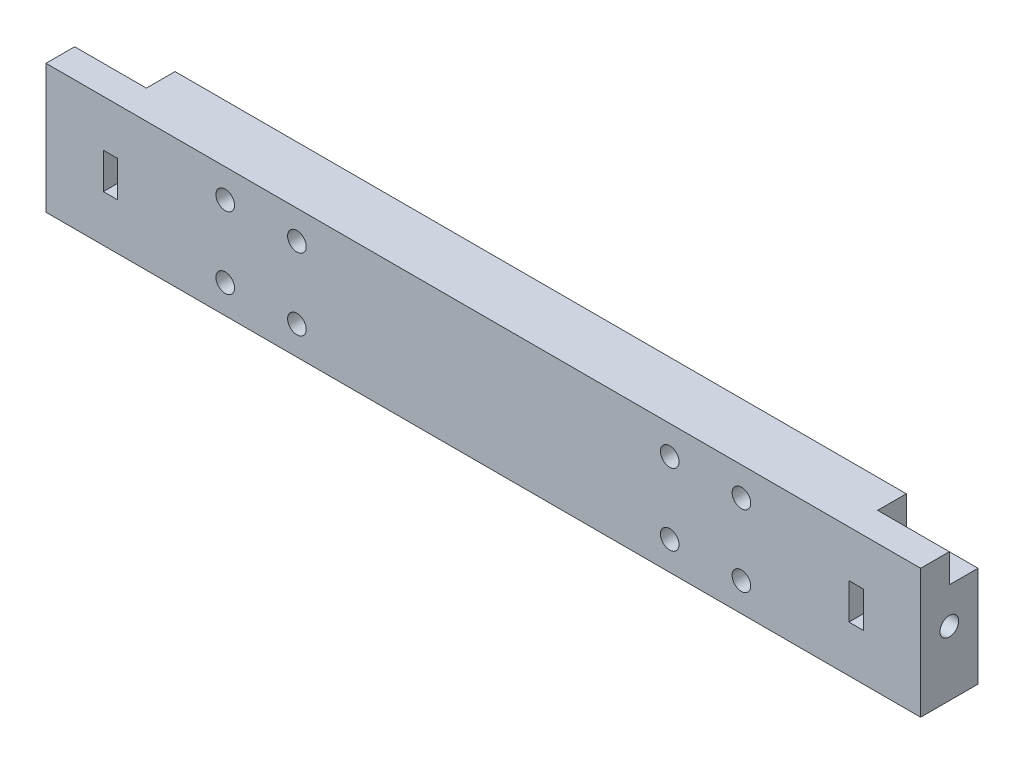
from build123d import *

# Parameters (mm, degrees)
SKETCH1_W           = 122
SKETCH1_H           = 18
SKETCH1_R           = 1.3
BOSS_EXTRUDE1_DEPTH = 8
CUT_EXTRUDE1_DEPTH  = 3
SKETCH3_W           = 10
SKETCH3_H           = 4
CUT_EXTRUDE2_DEPTH  = 4
SKETCH4_R           = 1.3
CUT_EXTRUDE3_DEPTH  = 10
SKETCH5_W           = 2
SKETCH5_H           = 5
CUT_EXTRUDE4_DEPTH  = 10


with BuildPart() as part:
    # Sketch1 → Boss-Extrude1 (new body)
    with BuildSketch(Plane.XY):
        Rectangle(SKETCH1_W, SKETCH1_H)
        with Locations((-26, 5)):
            Circle(SKETCH1_R, mode=Mode.SUBTRACT)
        with Locations((-36, 5)):
            Circle(SKETCH1_R, mode=Mode.SUBTRACT)
        with Locations((-26, -5)):
            Circle(SKETCH1_R, mode=Mode.SUBTRACT)
        with Locations((-36, -5)):
            Circle(SKETCH1_R, mode=Mode.SUBTRACT)
        with Locations((26, -5)):
            Circle(SKETCH1_R, mode=Mode.SUBTRACT)
        with Locations((36, -5)):
            Circle(SKETCH1_R, mode=Mode.SUBTRACT)
        with Locations((36, 5)):
            Circle(SKETCH1_R, mode=Mode.SUBTRACT)
        with Locations((26, 5)):
            Circle(SKETCH1_R, mode=Mode.SUBTRACT)
    extrude(amount=BOSS_EXTRUDE1_DEPTH)

    # Sketch2 → Cut-Extrude1 (cut)
    with BuildSketch(Plane(origin=(0, 0, 0), x_dir=(-1, 0, 0), z_dir=(0, 0, -1))):
        Polygon((-36, 2), (-33.401923789, 3.5), (-33.401923789, 6.5), (-36, 8), (-38.598076211, 6.5), (-38.598076211, 3.5), align=None)
        Polygon((-26, 2), (-23.401923789, 3.5), (-23.401923789, 6.5), (-26, 8), (-28.598076211, 6.5), (-28.598076211, 3.5), align=None)
        Polygon((-26, -8), (-23.401923789, -6.5), (-23.401923789, -3.5), (-26, -2), (-28.598076211, -3.5), (-28.598076211, -6.5), align=None)
        Polygon((-36, -8), (-33.401923789, -6.5), (-33.401923789, -3.5), (-36, -2), (-38.598076211, -3.5), (-38.598076211, -6.5), align=None)
        Polygon((26, 2), (28.598076211, 3.5), (28.598076211, 6.5), (26, 8), (23.401923789, 6.5), (23.401923789, 3.5), align=None)
        Polygon((26, -8), (28.598076211, -6.5), (28.598076211, -3.5), (26, -2), (23.401923789, -3.5), (23.401923789, -6.5), align=None)
        Polygon((36, -8), (38.598076211, -6.5), (38.598076211, -3.5), (36, -2), (33.401923789, -3.5), (33.401923789, -6.5), align=None)
        Polygon((36, 2), (38.598076211, 3.5), (38.598076211, 6.5), (36, 8), (33.401923789, 6.5), (33.401923789, 3.5), align=None)
    extrude(amount=-CUT_EXTRUDE1_DEPTH, mode=Mode.SUBTRACT)

    # Sketch3 → Cut-Extrude2 (cut)
    with BuildSketch(Plane(origin=(0, 0, 0), x_dir=(-1, 0, 0), z_dir=(0, 0, -1))):
        with Locations((-56, 7)):
            Rectangle(SKETCH3_W, SKETCH3_H)
        with Locations((56, 7)):
            Rectangle(SKETCH3_W, SKETCH3_H)
    extrude(amount=-CUT_EXTRUDE2_DEPTH, mode=Mode.SUBTRACT)

    # Sketch4 → Cut-Extrude3 (cut)
    with BuildSketch(Plane(origin=(61, 0, 0), x_dir=(0, 0, -1), z_dir=(1, 0, 0))):
        with Locations((-4, 0)):
            Circle(SKETCH4_R)
    cut_extrude3 = extrude(amount=-CUT_EXTRUDE3_DEPTH, mode=Mode.SUBTRACT)

    # Sketch5 → Cut-Extrude4 (cut)
    with BuildSketch(Plane(origin=(0, 0, 0), x_dir=(-1, 0, 0), z_dir=(0, 0, -1))):
        with Locations((-52, 0)):
            Rectangle(SKETCH5_W, SKETCH5_H)
    cut_extrude4 = extrude(amount=-CUT_EXTRUDE4_DEPTH, mode=Mode.SUBTRACT)

    # Mirror1: Cut-Extrude3, Cut-Extrude4 across plane
    add(cut_extrude3.mirror(Plane(origin=(0, 0, 0), x_dir=(0, 0, 1), z_dir=(1, 0, 0))), mode=Mode.SUBTRACT)
    add(cut_extrude4.mirror(Plane(origin=(0, 0, 0), x_dir=(0, 0, 1), z_dir=(1, 0, 0))), mode=Mode.SUBTRACT)


solid = part.part
